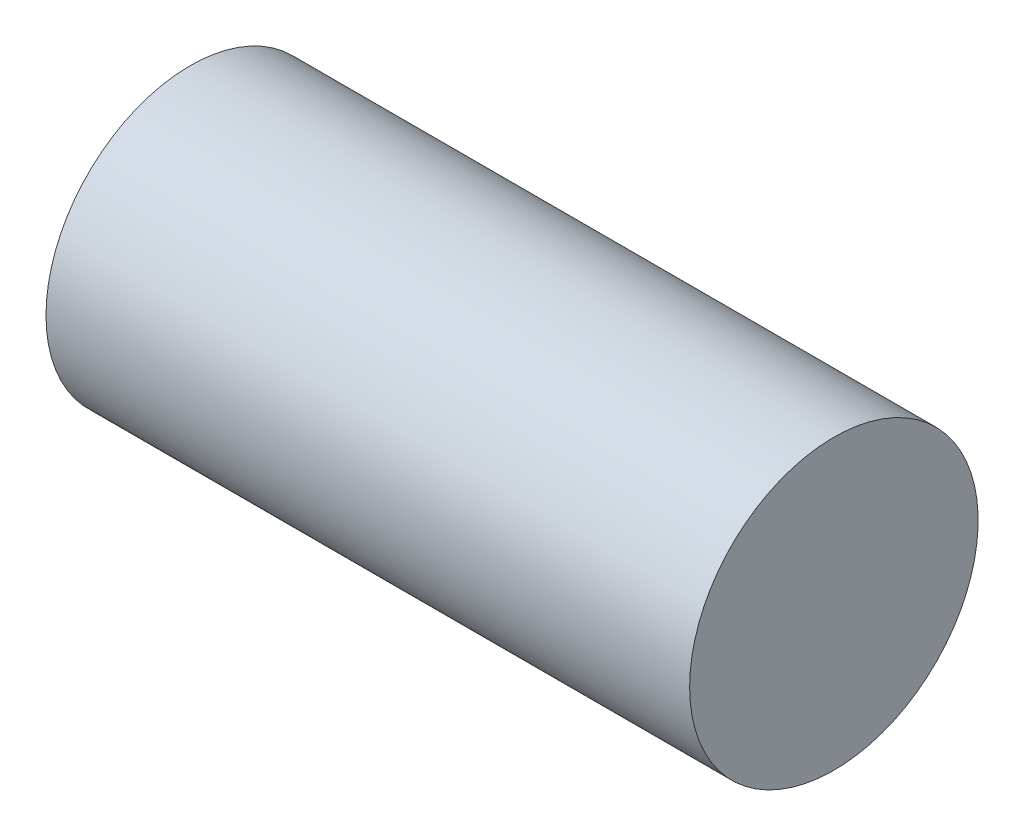
from build123d import *

# Parameters (mm, degrees)
SKETCH1_W = 58
SKETCH1_H = 13


with BuildPart() as part:
    # Sketch1 → Revolve1 (revolve)
    with BuildSketch(Plane(origin=(0, 0, 0), x_dir=(1, 0, 0), z_dir=(0, 1, 0))):
        with Locations((29, 6.5)):
            Rectangle(SKETCH1_W, SKETCH1_H)
    revolve(axis=Axis((0, 0, -13), (1, 0, 0)))


solid = part.part
